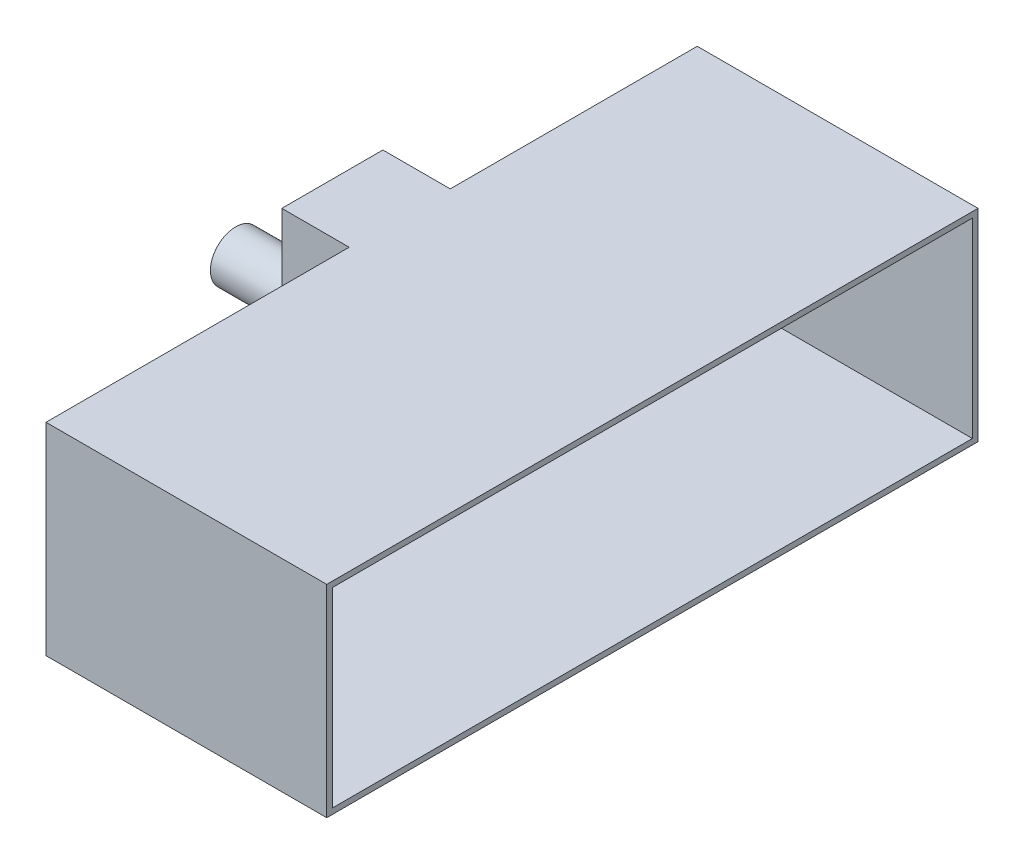
from build123d import *

# Parameters (mm, degrees)
SKETCH2_R           = 2.25
SKETCH2_R_2         = 1.75
BOSS_EXTRUDE1_DEPTH = 8.235963
SKETCH3_W           = 9
SKETCH3_H           = 18
SKETCH3_W_2         = 8
SKETCH3_H_2         = 17
BOSS_EXTRUDE2_DEPTH = 6
SKETCH3_3_W         = 8
SKETCH3_3_H         = 17
SKETCH3_3_R         = 1.75
BOSS_EXTRUDE4_DEPTH = 0.5
SKETCH4_W           = 26.5
SKETCH4_H           = 17
SKETCH4_W_2         = 0.5
SKETCH4_W_3         = 21.5
BOSS_EXTRUDE5_DEPTH = 0.5
BOSS_EXTRUDE6_DEPTH = 25


with BuildPart() as part:
    # Sketch2 → Boss-Extrude1 (new body)
    with BuildSketch(Plane(origin=(82, 0, 0), x_dir=(0, 0, -1), z_dir=(1, 0, 0))):
        with Locations((-66.879673477, 39.201031326)):
            Circle(SKETCH2_R)
        with Locations((-66.879673477, 39.201031326)):
            Circle(SKETCH2_R_2, mode=Mode.SUBTRACT)
    extrude(amount=BOSS_EXTRUDE1_DEPTH)


with BuildPart() as body_2:
    # Sketch3 → Boss-Extrude2 (new body)
    with BuildSketch(Plane(origin=(90.235962573, 0, 0), x_dir=(0, 0, -1), z_dir=(1, 0, 0))):
        with Locations((-66.504673477, 40.057518668)):
            Rectangle(SKETCH3_W, SKETCH3_H)
        with Locations((-66.504673477, 40.057518668)):
            Rectangle(SKETCH3_W_2, SKETCH3_H_2, mode=Mode.SUBTRACT)
    extrude(amount=BOSS_EXTRUDE2_DEPTH)

    # Sketch3_3 → Boss-Extrude4 (add)
    with BuildSketch(Plane(origin=(90.235962573, 0, 0), x_dir=(0, 0, -1), z_dir=(1, 0, 0))):
        with Locations((-66.504673477, 40.057518668)):
            Rectangle(SKETCH3_3_W, SKETCH3_3_H)
        with Locations((-66.879673477, 39.201031326)):
            Circle(SKETCH3_3_R, mode=Mode.SUBTRACT)
    extrude(amount=BOSS_EXTRUDE4_DEPTH)

    # Sketch4 → Boss-Extrude5 (add)
    with BuildSketch(Plane(origin=(96.235962573, 0, 0), x_dir=(0, 0, -1), z_dir=(1, 0, 0))):
        Polygon((-71.004673477, 49.057518668), (-98.004673477, 49.057518668), (-98.004673477, 31.057518668), (-71.004673477, 31.057518668), (-71.004673477, 31.557518668), (-97.504673477, 31.557518668), (-97.504673477, 48.557518668), (-71.004673477, 48.557518668), align=None)
        with Locations((-84.254673477, 40.057518668)):
            Rectangle(SKETCH4_W, SKETCH4_H)
        Polygon((-62.004673477, 49.057518668), (-71.004673477, 49.057518668), (-71.004673477, 48.557518668), (-70.504673477, 48.557518668), (-62.504673477, 48.557518668), (-62.004673477, 48.557518668), align=None)
        with Locations((-70.754673477, 40.057518668)):
            Rectangle(SKETCH4_W_2, SKETCH4_H)
        Polygon((-71.004673477, 31.557518668), (-71.004673477, 31.057518668), (-62.004673477, 31.057518668), (-62.004673477, 31.557518668), (-62.504673477, 31.557518668), (-70.504673477, 31.557518668), align=None)
        with Locations((-62.254673477, 40.057518668)):
            Rectangle(SKETCH4_W_2, SKETCH4_H)
        with Locations((-51.254673477, 40.057518668)):
            Rectangle(SKETCH4_W_3, SKETCH4_H)
        Polygon((-40.004673477, 49.057518668), (-62.004673477, 49.057518668), (-62.004673477, 48.557518668), (-40.504673477, 48.557518668), (-40.504673477, 31.557518668), (-62.004673477, 31.557518668), (-62.004673477, 31.057518668), (-40.004673477, 31.057518668), align=None)
    extrude(amount=BOSS_EXTRUDE5_DEPTH)

    # Sketch4_4 → Boss-Extrude6 (add)
    with BuildSketch(Plane(origin=(96.235962573, 0, 0), x_dir=(0, 0, -1), z_dir=(1, 0, 0))):
        Polygon((-62.004673477, 49.057518668), (-71.004673477, 49.057518668), (-71.004673477, 48.557518668), (-70.504673477, 48.557518668), (-62.504673477, 48.557518668), (-62.004673477, 48.557518668), align=None)
        Polygon((-71.004673477, 49.057518668), (-98.004673477, 49.057518668), (-98.004673477, 31.057518668), (-71.004673477, 31.057518668), (-71.004673477, 31.557518668), (-97.504673477, 31.557518668), (-97.504673477, 48.557518668), (-71.004673477, 48.557518668), align=None)
        Polygon((-40.004673477, 49.057518668), (-62.004673477, 49.057518668), (-62.004673477, 48.557518668), (-40.504673477, 48.557518668), (-40.504673477, 31.557518668), (-62.004673477, 31.557518668), (-62.004673477, 31.057518668), (-40.004673477, 31.057518668), align=None)
        Polygon((-71.004673477, 31.557518668), (-71.004673477, 31.057518668), (-62.004673477, 31.057518668), (-62.004673477, 31.557518668), (-62.504673477, 31.557518668), (-70.504673477, 31.557518668), align=None)
    extrude(amount=BOSS_EXTRUDE6_DEPTH)


solid = Compound([part.part, body_2.part])
